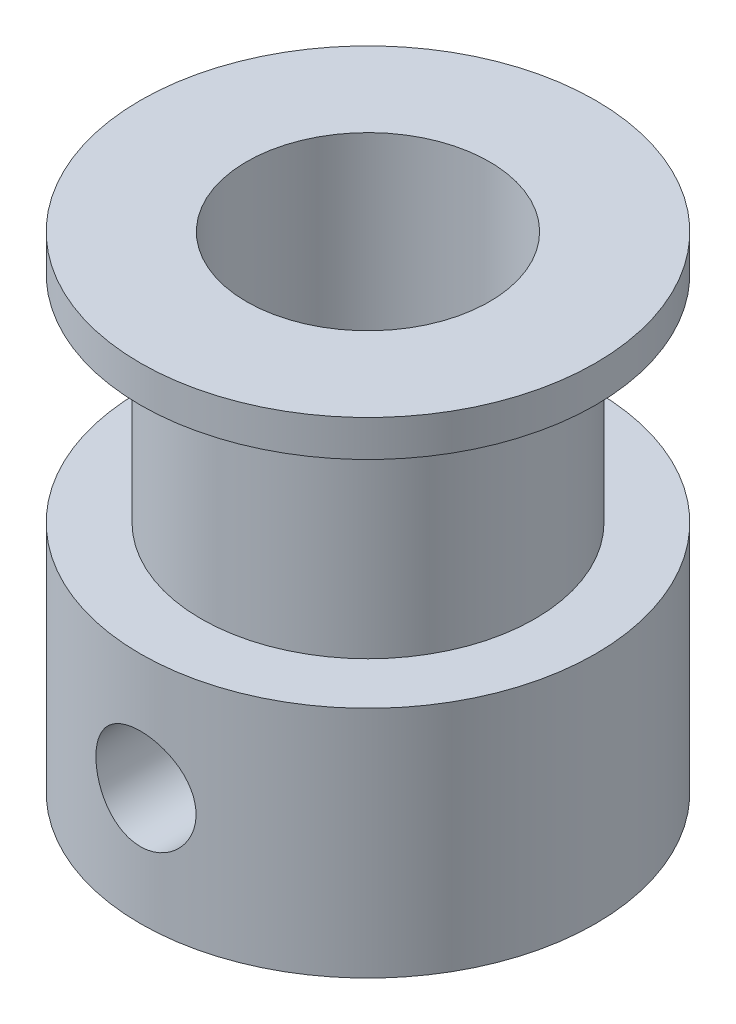
from build123d import *

# Parameters (mm, degrees)
CROQUIS1_R              = 7.5
SALIENTE_EXTRUIR1_DEPTH = 7.7
CROQUIS2_R              = 5.5
SALIENTE_EXTRUIR2_DEPTH = 7.1
CROQUIS3_R              = 7.5
SALIENTE_EXTRUIR3_DEPTH = 1.2
CROQUIS4_R              = 4
CORTAR_EXTRUIR1_DEPTH   = 17
CROQUIS5_W              = 1.65
CROQUIS5_H              = 7.501
MATRIZC1_COUNT          = 2
MATRIZC1_ANGLE          = 90


with BuildPart() as part:
    # Croquis1 → Saliente-Extruir1 (new body)
    with BuildSketch(Plane(origin=(0, 0, 0), x_dir=(1, 0, 0), z_dir=(0, 1, 0))):
        Circle(CROQUIS1_R)
    extrude(amount=SALIENTE_EXTRUIR1_DEPTH)

    # Croquis2 → Saliente-Extruir2 (add)
    with BuildSketch(Plane(origin=(0, 7.7, 0), x_dir=(1, 0, 0), z_dir=(0, 1, 0))):
        Circle(CROQUIS2_R)
    extrude(amount=SALIENTE_EXTRUIR2_DEPTH)

    # Croquis3 → Saliente-Extruir3 (add)
    with BuildSketch(Plane(origin=(0, 14.8, 0), x_dir=(1, 0, 0), z_dir=(0, 1, 0))):
        Circle(CROQUIS3_R)
    extrude(amount=SALIENTE_EXTRUIR3_DEPTH)

    # Croquis4 → Cortar-Extruir1 (cut, through all)
    with BuildSketch(Plane(origin=(0, 16, 0), x_dir=(1, 0, 0), z_dir=(0, 1, 0))):
        Circle(CROQUIS4_R)
    extrude(amount=-CORTAR_EXTRUIR1_DEPTH, mode=Mode.SUBTRACT)

    # Croquis5 → Taladro roscado M31 (definir posicio) (revolve, cut)
    with BuildSketch(Plane(origin=(0, 3.85, 0), x_dir=(0, 1, 0), z_dir=(1, 0, 0))):
        with Locations((0.825, 3.7505)):
            Rectangle(CROQUIS5_W, CROQUIS5_H)
    taladro_roscado_m31_definir_posicio = revolve(axis=Axis((0, 3.85, -6.35), (0, 0, 1)), mode=Mode.SUBTRACT)

    # MatrizC1: Taladro roscado M31 (definir posicio) ×2 about axis
    matrizc1_axis = Axis((0, 7.7, 0), (0, -1, 0))
    for i in range(1, MATRIZC1_COUNT):
        add(taladro_roscado_m31_definir_posicio.rotate(matrizc1_axis, i * MATRIZC1_ANGLE / (MATRIZC1_COUNT - 1)), mode=Mode.SUBTRACT)


solid = part.part
